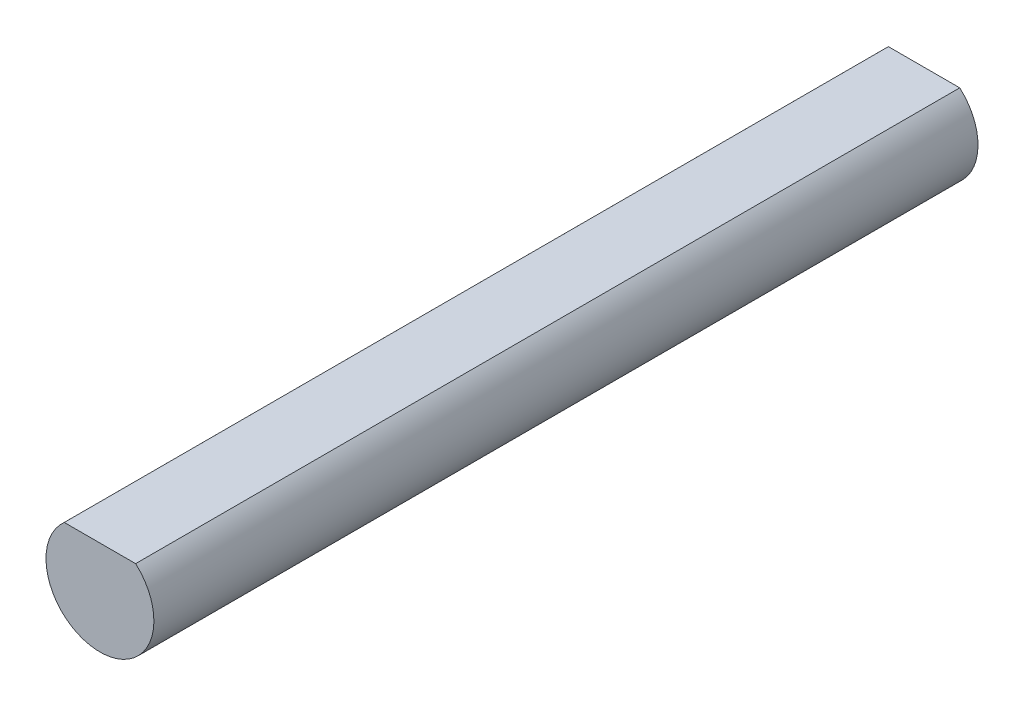
from build123d import *

# Parameters (mm, degrees)
EXTRUDE1_DEPTH = 30.55


with BuildPart() as part:
    # Sketch1 → Extrude1 (new body)
    with BuildSketch(Plane.XY):
        with BuildLine():
            Line((-1.322875656, 1.5), (1.322875656, 1.5))
            ThreePointArc((1.322875656, 1.5), (0, -2), (-1.322875656, 1.5))
        make_face()
    extrude(amount=-EXTRUDE1_DEPTH)


solid = part.part
